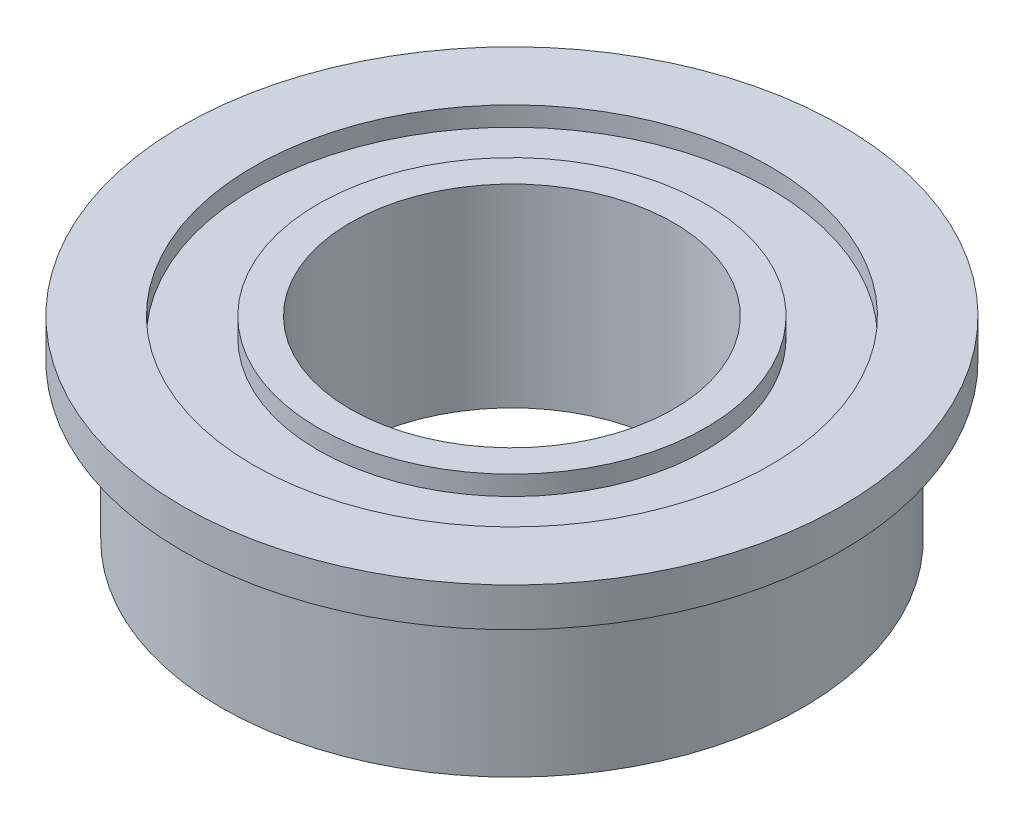
from build123d import *

# Parameters (mm, degrees)
EXTRUDE_1_DEPTH        = 1.5
EXTRUDE_1_DEPTH_BACK   = 1.5
SKETCH_1_R             = 3
SKETCH_1_R_2           = 2.5
EXTRUDE_1_2_DEPTH      = 1.5
EXTRUDE_1_2_DEPTH_BACK = 1.5
SKETCH_1_R_3           = 4.5
SKETCH_1_R_4           = 4
EXTRUDE_2_DEPTH        = 1.2
EXTRUDE_2_DEPTH_BACK   = 1.2
SKETCH_2_R             = 4
SKETCH_2_R_2           = 3
SKETCH_3_R             = 5.1
SKETCH_3_R_2           = 4.5
EXTRUDE_3_DEPTH        = 0.6


with BuildPart() as part:
    # 草图1 → 凸台-拉伸1 (new, two sides: drawn at the far end of the back side and taken through both)
    with BuildSketch(Plane(origin=(0, 0, 0), x_dir=(1, 0, 0), z_dir=(0, 1, 0)).offset(-EXTRUDE_1_DEPTH_BACK)):
        Circle(SKETCH_1_R)
        Circle(SKETCH_1_R_2, mode=Mode.SUBTRACT)
    extrude(amount=EXTRUDE_1_DEPTH + EXTRUDE_1_DEPTH_BACK)



with BuildPart() as body_2:
    # 草图1 → Extrude 1 2 (new, two sides: drawn at the far end of the back side and taken through both)
    with BuildSketch(Plane(origin=(0, 0, 0), x_dir=(1, 0, 0), z_dir=(0, 1, 0)).offset(-EXTRUDE_1_2_DEPTH_BACK)):
        Circle(SKETCH_1_R_3)
        Circle(SKETCH_1_R_4, mode=Mode.SUBTRACT)
    extrude(amount=EXTRUDE_1_2_DEPTH + EXTRUDE_1_2_DEPTH_BACK)


with BuildPart() as part_1:
    add(part.part)

    add(body_2.part)  # 凸台-拉伸2 merges body 2
    # 草图2 → 凸台-拉伸2 (add, two sides: drawn at the far end of the back side and taken through both)
    with BuildSketch(Plane(origin=(0, 0, 0), x_dir=(1, 0, 0), z_dir=(0, 1, 0)).offset(-EXTRUDE_2_DEPTH_BACK)):
        Circle(SKETCH_2_R)
        Circle(SKETCH_2_R_2, mode=Mode.SUBTRACT)
    extrude(amount=EXTRUDE_2_DEPTH + EXTRUDE_2_DEPTH_BACK)

    # 草图3 → 凸台-拉伸3 (add)
    with BuildSketch(Plane(origin=(0, 1.5, 0), x_dir=(1, 0, 0), z_dir=(0, 1, 0))):
        Circle(SKETCH_3_R)
        Circle(SKETCH_3_R_2, mode=Mode.SUBTRACT)
    extrude(amount=-EXTRUDE_3_DEPTH)


solid = part_1.part
